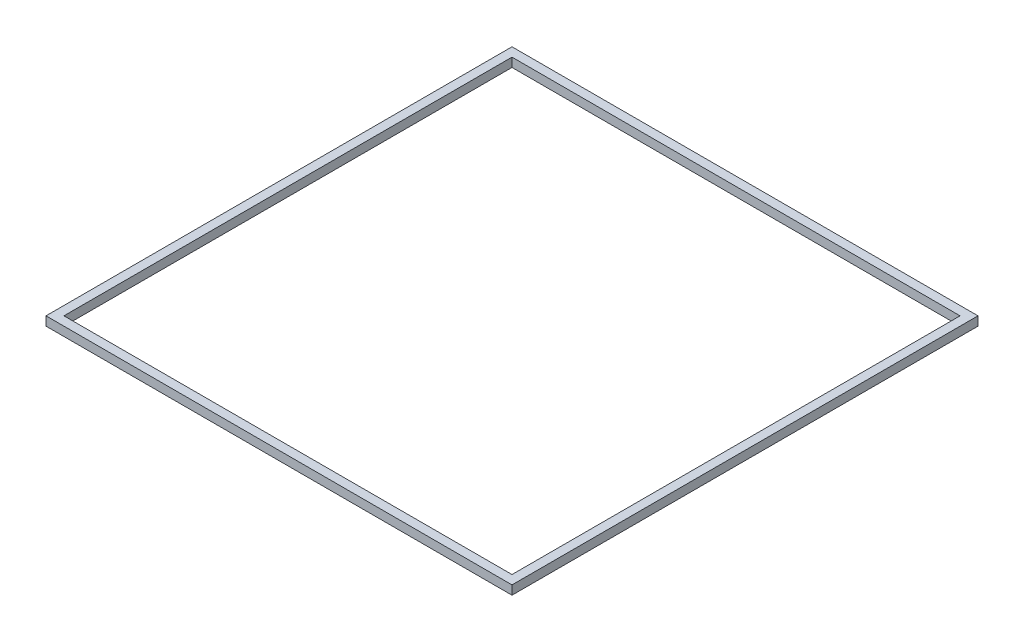
from build123d import *

# Parameters (mm, degrees)
SKETCH1_W           = 104
SKETCH1_H           = 104
SKETCH1_W_2         = 100
SKETCH1_H_2         = 100
BOSS_EXTRUDE1_DEPTH = 2


with BuildPart() as part:
    # Sketch1 → Boss-Extrude1 (new body)
    with BuildSketch(Plane(origin=(0, 0, 0), x_dir=(1, 0, 0), z_dir=(0, 1, 0))):
        Rectangle(SKETCH1_W, SKETCH1_H)
        Rectangle(SKETCH1_W_2, SKETCH1_H_2, mode=Mode.SUBTRACT)
    extrude(amount=BOSS_EXTRUDE1_DEPTH)


solid = part.part
